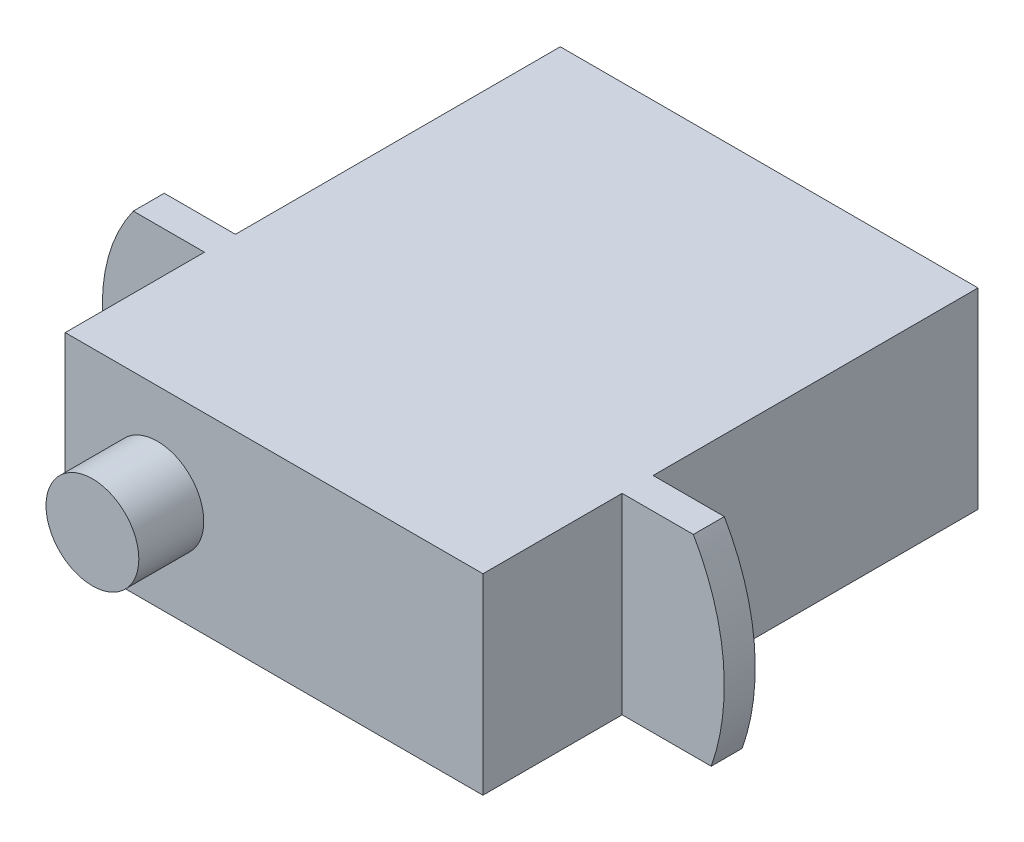
from build123d import *

# Parameters (mm, degrees)
SKETCH_1_W          = 13.5
SKETCH_1_H          = 16
EXTRUDE_1_DEPTH     = 6.2
SKETCH_2_R          = 1.5
EXTRUDE_2_DEPTH     = 2.1
SKETCH_3_W          = 1
SKETCH_3_H          = 6.2
EXTRUDE_3_DEPTH     = 3.3
CUT_EXTRUDE_1_DEPTH = 4
SKETCH_6_W          = 1
SKETCH_6_H          = 6.2
EXTRUDE_4_DEPTH     = 3.3
CUT_EXTRUDE_2_DEPTH = 4


with BuildPart() as part:
    # 草图1 → 凸台-拉伸1 (new body)
    with BuildSketch(Plane(origin=(0, 0, 0), x_dir=(1, 0, 0), z_dir=(0, 1, 0))):
        with Locations((-9.627906977, -0.837209302)):
            Rectangle(SKETCH_1_W, SKETCH_1_H)
    extrude(amount=EXTRUDE_1_DEPTH)

    # 草图2 → 凸台-拉伸2 (add)
    with BuildSketch(Plane.XY.offset(8.837209302)):
        with Locations((-13.399361956, 3.148420963)):
            Circle(SKETCH_2_R)
    extrude(amount=EXTRUDE_2_DEPTH)

    # 草图3 → 凸台-拉伸3 (add)
    with BuildSketch(Plane.ZY.offset(16.377906977)):
        with Locations((3.837209302, 3.1)):
            Rectangle(SKETCH_3_W, SKETCH_3_H)
    extrude(amount=EXTRUDE_3_DEPTH)

    # 草图5 → 切除-拉伸1 (cut)
    with BuildSketch(Plane.XY.offset(4.337209302)):
        with BuildLine():
            ThreePointArc((-19.677906977, 3.1), (-19.421721194, 4.728649747), (-18.677906977, 6.2))
            Line((-18.677906977, 6.2), (-19.677906977, 6.2))
            Line((-19.677906977, 6.2), (-19.677906977, 3.1))
        make_face()
        with BuildLine():
            ThreePointArc((-18.677906977, 0), (-19.421721194, 1.471350253), (-19.677906977, 3.1))
            Line((-19.677906977, 3.1), (-19.677906977, 0))
            Line((-19.677906977, 0), (-18.677906977, 0))
        make_face()
    extrude(amount=-CUT_EXTRUDE_1_DEPTH, mode=Mode.SUBTRACT)

    # 草图6 → 凸台-拉伸4 (add)
    with BuildSketch(Plane(origin=(-2.877906977, 0, 0), x_dir=(0, 0, -1), z_dir=(1, 0, 0))):
        with Locations((-3.837209302, 3.1)):
            Rectangle(SKETCH_6_W, SKETCH_6_H)
    extrude(amount=EXTRUDE_4_DEPTH)

    # 草图10 → 切除-拉伸2 (cut)
    with BuildSketch(Plane.XY.offset(4.337209302)):
        with BuildLine():
            Line((0.422093023, 0), (0.422093023, 2.47192447))
            ThreePointArc((0.422093023, 2.47192447), (0.315811593, 1.218073092), (0, 0))
            Line((0, 0), (0.422093023, 0))
        make_face()
        with BuildLine():
            Line((0.422093023, 6.2), (-0.577906977, 6.2))
            ThreePointArc((-0.577906977, 6.2), (0.167750994, 4.401856278), (0.422093023, 2.47192447))
            Line((0.422093023, 2.47192447), (0.422093023, 6.2))
        make_face()
    extrude(amount=-CUT_EXTRUDE_2_DEPTH, mode=Mode.SUBTRACT)


solid = part.part
